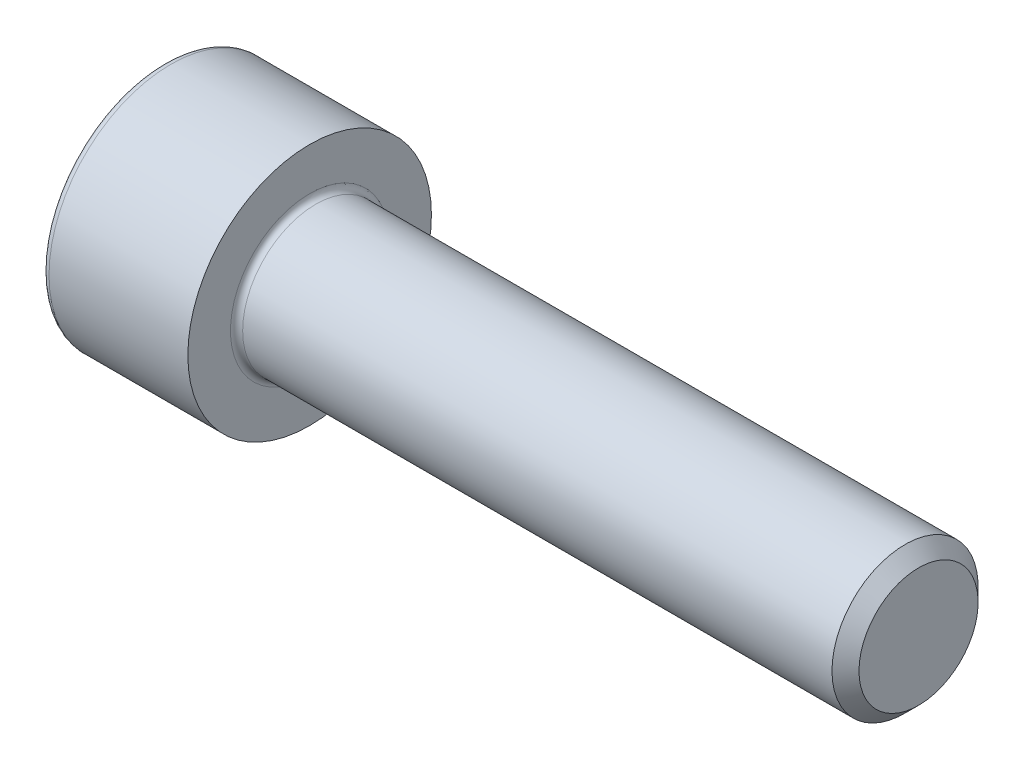
from build123d import *

# Parameters (mm, degrees)
FILLET1_R   = 0.25
FILLET2_R   = 0.3
HEX_2_DEPTH = 3


with BuildPart() as part:
    # BodySke → Base-Revolve (revolve)
    with BuildSketch(Plane.XY, mode=Mode.PRIVATE) as base_revolve_sk:
        Polygon((0, 0), (0, 5), (6, 5), (6, 3), (30.4455, 3), (31, 2.4455), (31, 0), align=None)
    revolve(base_revolve_sk.sketch.rotate(Axis((-31.75, 0, 0), (1, 0, 0)), 90), axis=Axis((-31.75, 0, 0), (1, 0, 0)))  # turned: the seam where the file's is

    # Fillet1
    fillet1_edges = [part.edges().sort_by_distance(p)[0] for p in [
        (6, 0, -3),
    ]]
    fillet(fillet1_edges, radius=FILLET1_R)

    # Fillet2
    fillet2_edges = [part.edges().sort_by_distance(p)[0] for p in [
        (0, 0, -5),
    ]]
    fillet(fillet2_edges, radius=FILLET2_R)

    # Sketch2 → Hex-PreBroach (revolve, cut)
    with BuildSketch(Plane.XY, mode=Mode.PRIVATE) as hex_prebroach_sk:
        Polygon((0, 2.542), (3, 2.542), (4.467624384, 0), (0, 0), align=None)
    revolve(hex_prebroach_sk.sketch.rotate(Axis((0, 0, 0), (1, 0, 0)), 90), axis=Axis((0, 0, 0), (1, 0, 0)), mode=Mode.SUBTRACT)  # turned: the seam where the file's is

    # Sketch3 → Hex 2 (cut)
    with BuildSketch(Plane(origin=(0, 0, 0), x_dir=(0, 0.5, 0.866025404), z_dir=(-1, 0, 0))):
        Polygon((1.467624384, 2.542), (-1.467624384, 2.542), (-2.935248769, 0), (-1.467624384, -2.542), (1.467624384, -2.542), (2.935248769, 0), align=None)
    extrude(amount=-HEX_2_DEPTH, mode=Mode.SUBTRACT)


solid = part.part
